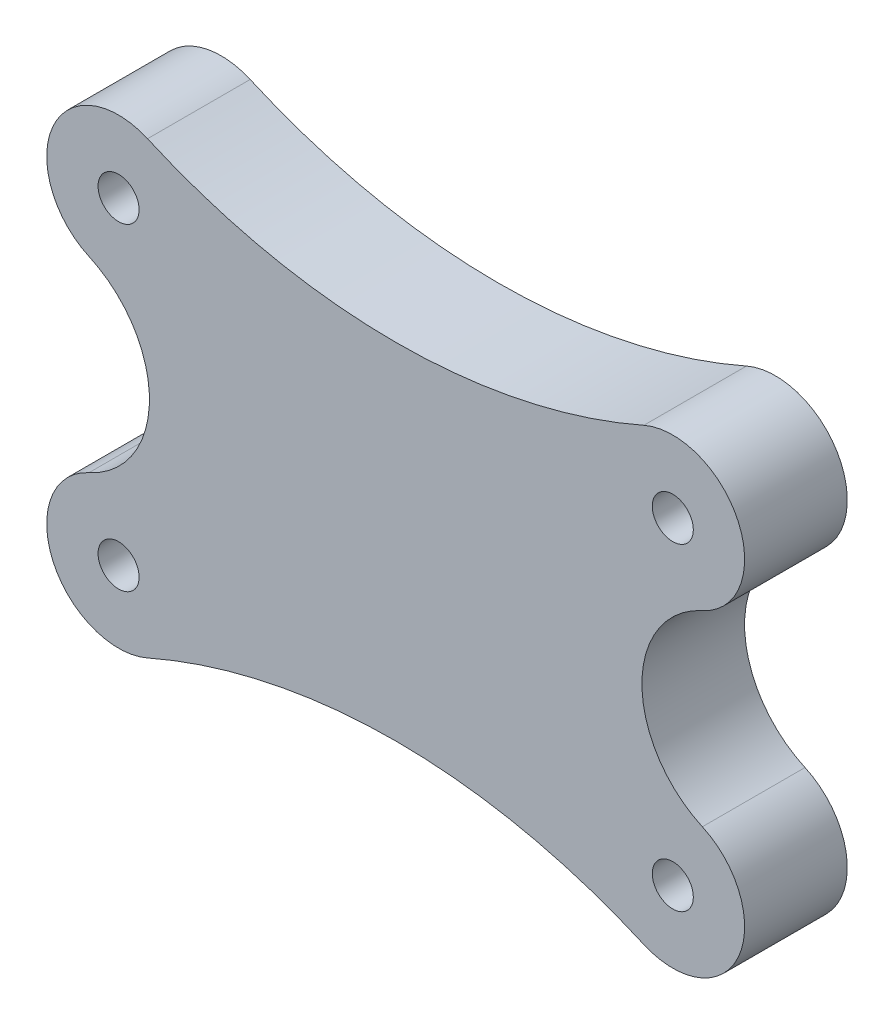
from build123d import *

# Parameters (mm, degrees)
ESQUISSE1_W        = 34
ESQUISSE1_H        = 22.5
ESQUISSE1_R        = 1
BOSS_EXTRU_1_DEPTH = 5
CUT_EXTRUDE1_DEPTH = 10


with BuildPart() as part:
    # Esquisse1 → Boss.-Extru.1 (new body)
    with BuildSketch(Plane.XY):
        with Locations((-17, 11.25)):
            Rectangle(ESQUISSE1_W, ESQUISSE1_H)
        with Locations((-30.5, 19)):
            Circle(ESQUISSE1_R, mode=Mode.SUBTRACT)
        with Locations((-3.5, 19)):
            Circle(ESQUISSE1_R, mode=Mode.SUBTRACT)
        with Locations((-3.5, 3.5)):
            Circle(ESQUISSE1_R, mode=Mode.SUBTRACT)
        with Locations((-30.5, 3.5)):
            Circle(ESQUISSE1_R, mode=Mode.SUBTRACT)
    extrude(amount=BOSS_EXTRU_1_DEPTH)

    # Sketch1 → Cut-Extrude1 (cut)
    with BuildSketch(Plane(origin=(0, 0, 0), x_dir=(-1, 0, 0), z_dir=(0, 0, -1))):
        Polygon((35.959040793, 25.036749556), (37.525504355, -3.285522646), (-6.460348748, -5.71831602), (-8.02681231, 22.603956182), align=None)
        with BuildLine():
            ThreePointArc((31.940553528, 15.810202901), (33.696545455, 20.425516451), (29.089552239, 22.203222926))
            ThreePointArc((29.089552239, 22.203222926), (17, 19.659419434), (4.910447761, 22.203222926))
            ThreePointArc((4.910447761, 22.203222926), (0.303454545, 20.425516451), (2.059446472, 15.810202901))
            ThreePointArc((2.059446472, 15.810202901), (5.003675676, 11.25), (2.059446472, 6.689797099))
            ThreePointArc((2.059446472, 6.689797099), (0.303454545, 2.074483549), (4.910447761, 0.296777074))
            ThreePointArc((4.910447761, 0.296777074), (17, 2.840580566), (29.089552239, 0.296777074))
            ThreePointArc((29.089552239, 0.296777074), (33.696545455, 2.074483549), (31.940553528, 6.689797099))
            ThreePointArc((31.940553528, 6.689797099), (28.996324324, 11.25), (31.940553528, 15.810202901))
        make_face(mode=Mode.SUBTRACT)
    extrude(amount=-CUT_EXTRUDE1_DEPTH, mode=Mode.SUBTRACT)


solid = part.part
